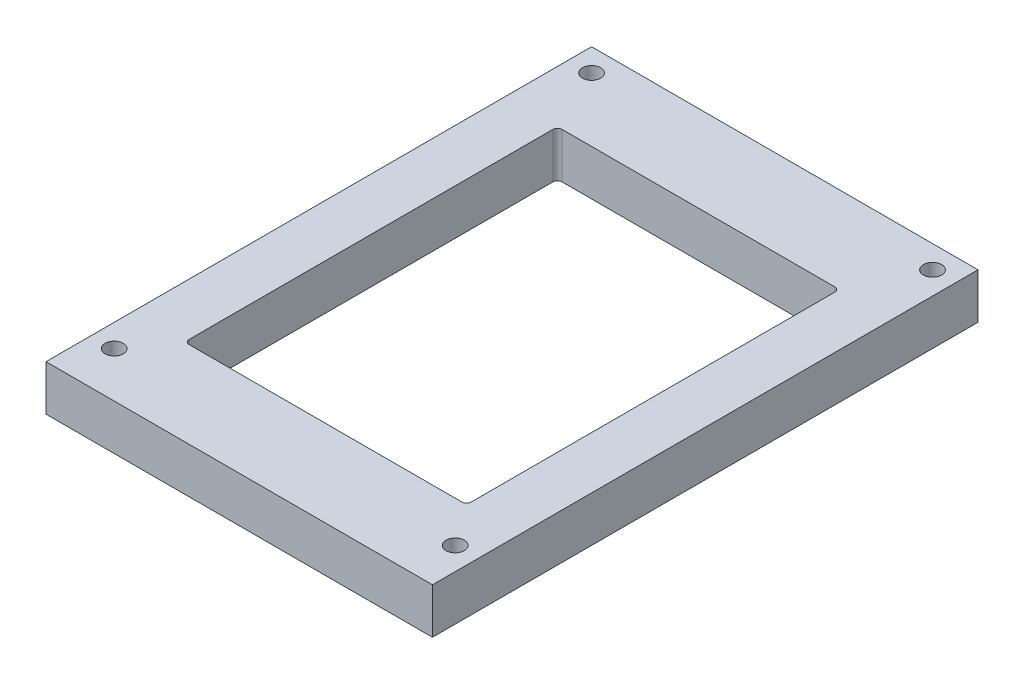
from build123d import *

# Parameters (mm, degrees)
SKETCH1_W           = 85
SKETCH1_H           = 120
BOSS_EXTRUDE1_DEPTH = 10
SKETCH2_W           = 62
SKETCH2_H           = 82
CUT_EXTRUDE1_DEPTH  = 10
FILLET1_R           = 1
SKETCH3_R           = 2
CUT_EXTRUDE2_DEPTH  = 5
SKETCH4_R           = 1
CUT_EXTRUDE3_DEPTH  = 5


with BuildPart() as part:
    # Sketch1 → Boss-Extrude1 (new body)
    with BuildSketch(Plane(origin=(0, 0, 0), x_dir=(1, 0, 0), z_dir=(0, 1, 0))):
        Rectangle(SKETCH1_W, SKETCH1_H)
    extrude(amount=BOSS_EXTRUDE1_DEPTH)

    # Sketch2 → Cut-Extrude1 (cut)
    with BuildSketch(Plane(origin=(0, 10, 0), x_dir=(1, 0, 0), z_dir=(0, 1, 0))):
        Rectangle(SKETCH2_W, SKETCH2_H)
    extrude(amount=-CUT_EXTRUDE1_DEPTH, mode=Mode.SUBTRACT)

    # Fillet1
    fillet1_edges = [part.edges().sort_by_distance(p)[0] for p in [
        (31, 5, -41),
        (31, 5, 41),
        (-31, 5, 41),
        (-31, 5, -41),
    ]]
    fillet(fillet1_edges, radius=FILLET1_R)

    # Sketch3 → Cut-Extrude2 (cut)
    with BuildSketch(Plane(origin=(0, 10, 0), x_dir=(1, 0, 0), z_dir=(0, 1, 0))):
        with Locations((-37.5, -50)):
            Circle(SKETCH3_R)
        with Locations((-37.5, 55)):
            Circle(SKETCH3_R)
        with Locations((37.5, 55)):
            Circle(SKETCH3_R)
        with Locations((37.5, -50)):
            Circle(SKETCH3_R)
    extrude(amount=-CUT_EXTRUDE2_DEPTH, mode=Mode.SUBTRACT)

    # Sketch4 → Cut-Extrude3 (cut)
    with BuildSketch(Plane(origin=(0, 5, 0), x_dir=(1, 0, 0), z_dir=(0, 1, 0))):
        with Locations((-37.5, -50)):
            Circle(SKETCH4_R)
        with Locations((37.5, -50)):
            Circle(SKETCH4_R)
        with Locations((37.5, 55)):
            Circle(SKETCH4_R)
        with Locations((-37.5, 55)):
            Circle(SKETCH4_R)
    extrude(amount=-CUT_EXTRUDE3_DEPTH, mode=Mode.SUBTRACT)


solid = part.part
